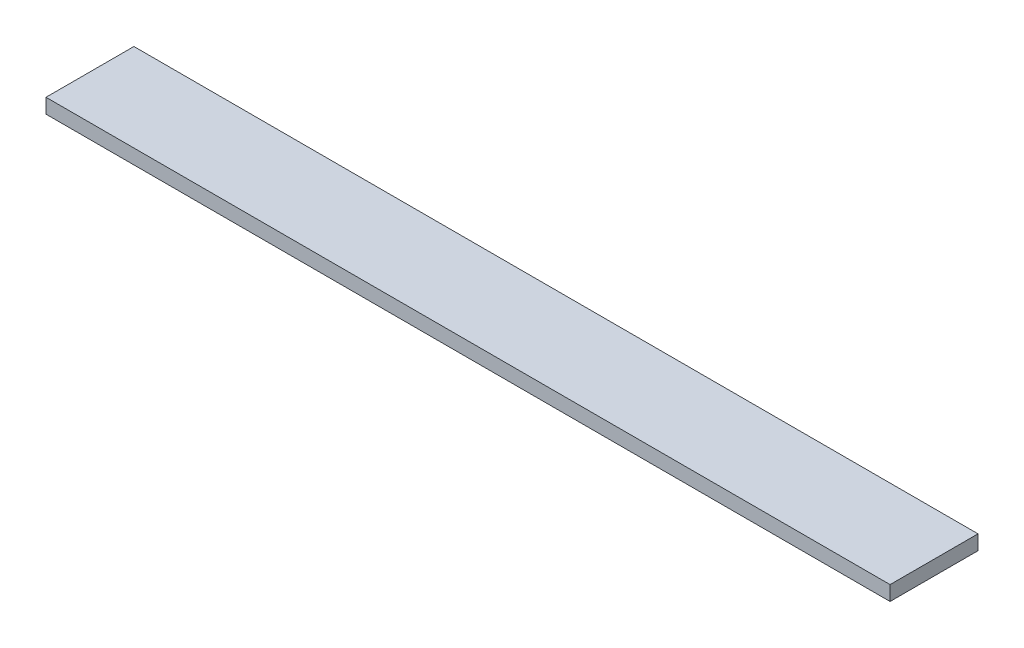
from build123d import *

# Parameters (mm, degrees)
SKETCH1_W           = 914.4
SKETCH1_H           = 95.25
BOSS_EXTRUDE1_DEPTH = 15.875


with BuildPart() as part:
    # Sketch1 → Boss-Extrude1 (new body)
    with BuildSketch(Plane(origin=(0, 0, 0), x_dir=(1, 0, 0), z_dir=(0, 1, 0))):
        with Locations((457.2, 47.625)):
            Rectangle(SKETCH1_W, SKETCH1_H)
    extrude(amount=BOSS_EXTRUDE1_DEPTH)


solid = part.part
